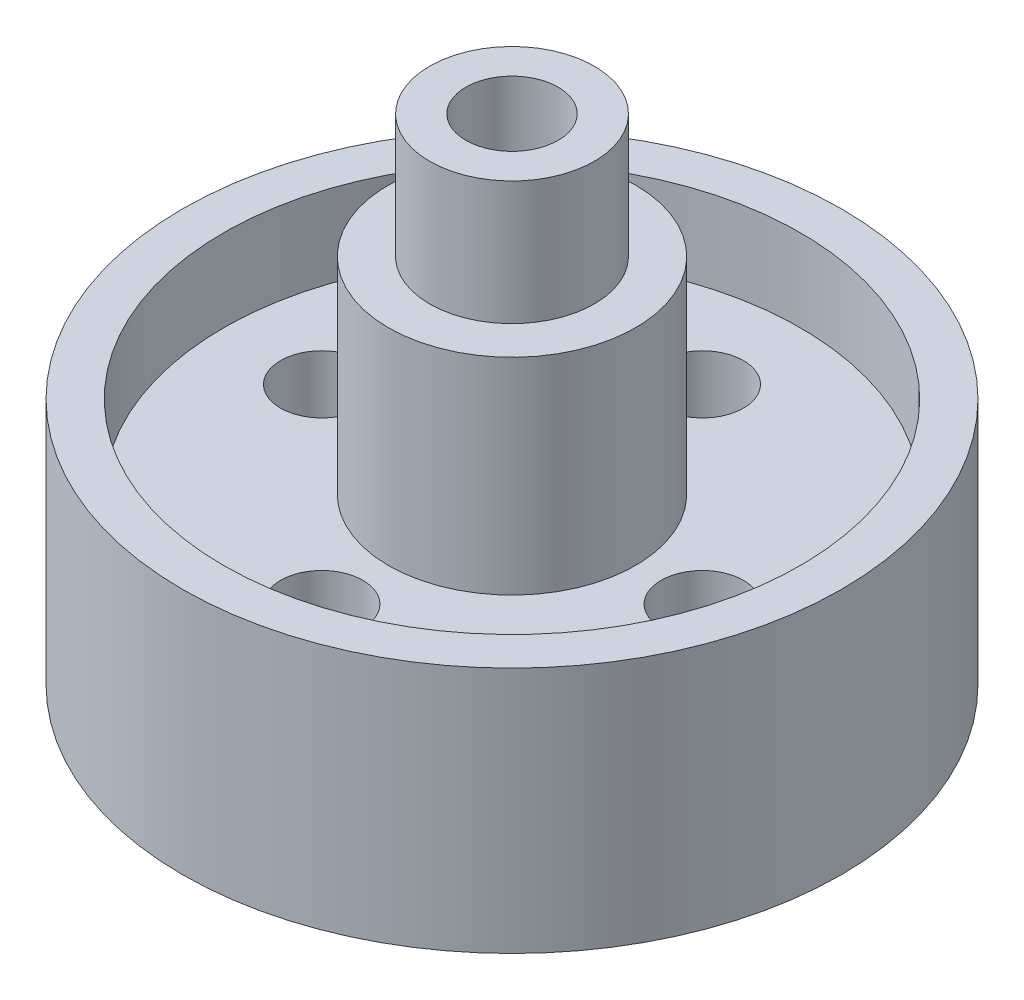
from build123d import *

# Parameters (mm, degrees)
SKETCH1_R           = 50.8
SKETCH1_R_2         = 44.45
BOSS_EXTRUDE1_DEPTH = 38.1
SKETCH1_4_R         = 44.45
SKETCH1_4_R_2       = 6.35
SKETCH1_4_R_3       = 19.05
BOSS_EXTRUDE3_DEPTH = 25.4
SKETCH1_5_R         = 19.05
SKETCH1_5_R_2       = 12.7
BOSS_EXTRUDE4_DEPTH = 57.15
SKETCH1_6_R         = 12.7
SKETCH1_6_R_2       = 7.112
BOSS_EXTRUDE5_DEPTH = 76.2


with BuildPart() as part:
    # Sketch1 → Boss-Extrude1 (new body)
    with BuildSketch(Plane(origin=(0, 0, 0), x_dir=(1, 0, 0), z_dir=(0, 1, 0))):
        Circle(SKETCH1_R)
        Circle(SKETCH1_R_2, mode=Mode.SUBTRACT)
    extrude(amount=BOSS_EXTRUDE1_DEPTH)

    # Sketch1_4 → Boss-Extrude3 (add)
    with BuildSketch(Plane(origin=(0, 0, 0), x_dir=(1, 0, 0), z_dir=(0, 1, 0))):
        Circle(SKETCH1_4_R)
        with Locations((29.337, 0)):
            Circle(SKETCH1_4_R_2, mode=Mode.SUBTRACT)
        with Locations((0, -29.337)):
            Circle(SKETCH1_4_R_2, mode=Mode.SUBTRACT)
        with Locations((-29.337, 0)):
            Circle(SKETCH1_4_R_2, mode=Mode.SUBTRACT)
        with Locations((0, 29.337)):
            Circle(SKETCH1_4_R_2, mode=Mode.SUBTRACT)
        Circle(SKETCH1_4_R_3, mode=Mode.SUBTRACT)
    extrude(amount=BOSS_EXTRUDE3_DEPTH)

    # Sketch1_5 → Boss-Extrude4 (add)
    with BuildSketch(Plane(origin=(0, 0, 0), x_dir=(1, 0, 0), z_dir=(0, 1, 0))):
        Circle(SKETCH1_5_R)
        Circle(SKETCH1_5_R_2, mode=Mode.SUBTRACT)
    extrude(amount=BOSS_EXTRUDE4_DEPTH)

    # Sketch1_6 → Boss-Extrude5 (add)
    with BuildSketch(Plane(origin=(0, 0, 0), x_dir=(1, 0, 0), z_dir=(0, 1, 0))):
        Circle(SKETCH1_6_R)
        Circle(SKETCH1_6_R_2, mode=Mode.SUBTRACT)
    extrude(amount=BOSS_EXTRUDE5_DEPTH)


solid = part.part
